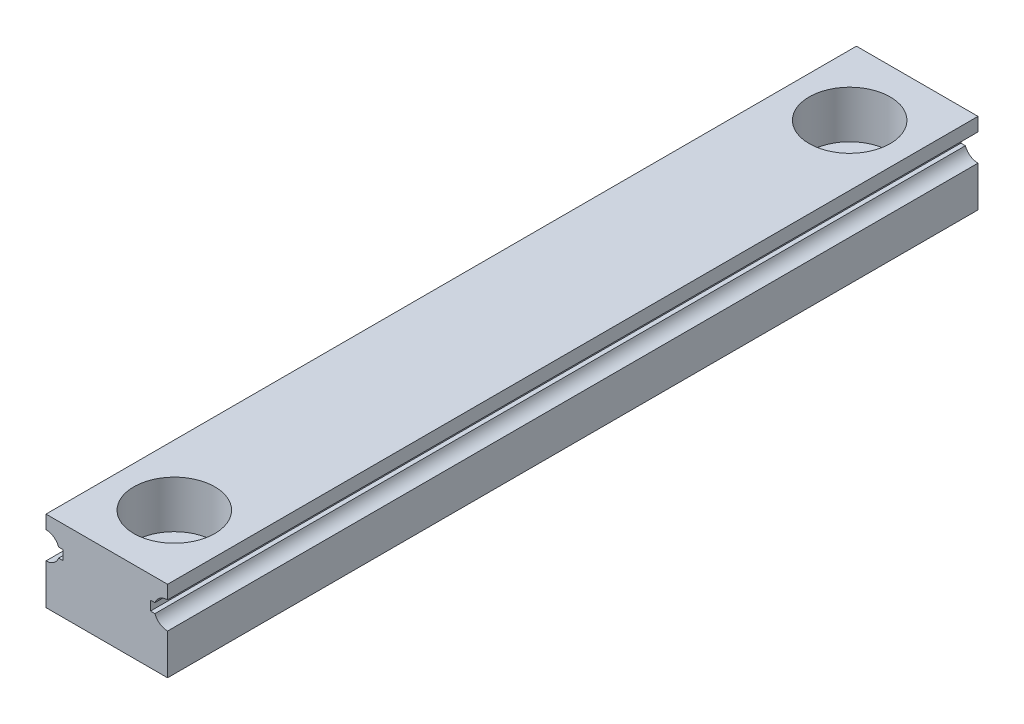
from build123d import *

# Parameters (mm, degrees)
EXTRUDE1_DEPTH  = 60
SKETCH2_R       = 3
EXTRUDE2_DEPTH  = 3.5
SKETCH_R        = 1.75
EXTRUDE3_DEPTH  = 61.466933112
LPATTERN1_COUNT = 45
LPATTERN1_PITCH = 50


with BuildPart() as part:
    # Sketch1 → Extrude1 (new body)
    with BuildSketch(Plane.XY):
        with BuildLine():
            Line((-4.5, -3), (4.5, -3))
            Line((4.5, -3), (4.5, 0))
            ThreePointArc((4.5, 0), (3.93077967, 0.177814974), (3.563991137, 0.648023568))
            Line((3.563991137, 0.648023568), (3.235073025, 0.648023568))
            Line((3.235073025, 0.648023568), (3.235073025, 1.351976432))
            Line((3.235073025, 1.351976432), (3.563991137, 1.351976432))
            ThreePointArc((3.563991137, 1.351976432), (3.93077967, 1.822185026), (4.5, 2))
            Line((4.5, 2), (4.5, 3))
            Line((4.5, 3), (-4.5, 3))
            Line((-4.5, 3), (-4.5, 2))
            ThreePointArc((-4.5, 2), (-3.93077967, 1.822185026), (-3.563991137, 1.351976432))
            Line((-3.563991137, 1.351976432), (-3.235073025, 1.351976432))
            Line((-3.235073025, 1.351976432), (-3.235073025, 0.648023568))
            Line((-3.235073025, 0.648023568), (-3.563991137, 0.648023568))
            ThreePointArc((-3.563991137, 0.648023568), (-3.93077967, 0.177814974), (-4.5, 0))
            Line((-4.5, 0), (-4.5, -3))
        make_face()
    extrude(amount=EXTRUDE1_DEPTH)

    # Sketch2 → Extrude2 (cut)
    with BuildSketch(Plane(origin=(0, 3, 0), x_dir=(1, 0, 0), z_dir=(0, 1, 0))):
        with Locations((0, -5)):
            Circle(SKETCH2_R)
    extrude2 = extrude(amount=-EXTRUDE2_DEPTH, mode=Mode.SUBTRACT)

    # Sketch → Extrude3 (cut, through all)
    with BuildSketch(Plane(origin=(0, 3, 0), x_dir=(1, 0, 0), z_dir=(0, 1, 0))):
        with Locations((0, -5)):
            Circle(SKETCH_R)
    extrude3 = extrude(amount=-EXTRUDE3_DEPTH, mode=Mode.SUBTRACT)

    # LPattern1: Extrude2, Extrude3 ×45
    with Locations(*[(0, 0, i * LPATTERN1_PITCH) for i in range(1, LPATTERN1_COUNT)]):
        add(extrude2, mode=Mode.SUBTRACT)
        add(extrude3, mode=Mode.SUBTRACT)


solid = part.part
